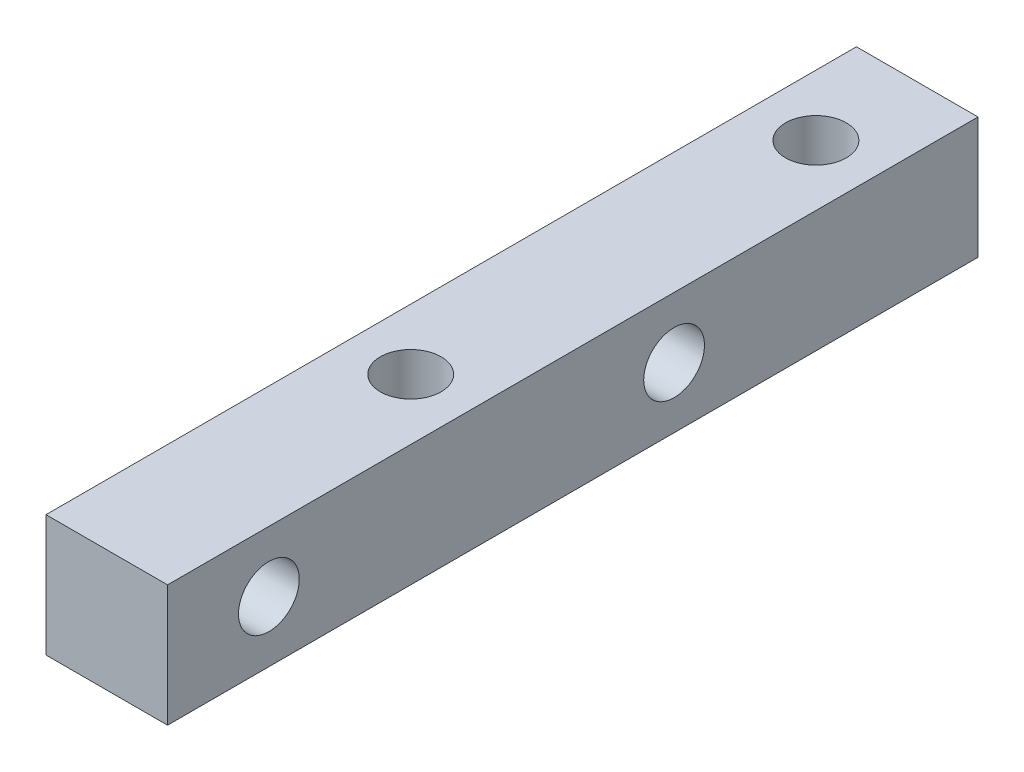
from build123d import *

# Parameters (mm, degrees)
SKETCH_1_W          = 6
SKETCH_1_H          = 6
EXTRUDE_1_DEPTH     = 40
SKETCH_2_R          = 1.5
CUT_EXTRUDE_1_DEPTH = 50
SKETCH_3_R          = 1.5
CUT_EXTRUDE_2_DEPTH = 50


with BuildPart() as part:
    # 草图1 → 凸台-拉伸1 (new body)
    with BuildSketch(Plane.XY):
        with Locations((3, 3)):
            Rectangle(SKETCH_1_W, SKETCH_1_H)
    extrude(amount=EXTRUDE_1_DEPTH)

    # 草图2 → 切除-拉伸1 (cut)
    with BuildSketch(Plane(origin=(0, 6, 0), x_dir=(1, 0, 0), z_dir=(0, 1, 0))):
        with Locations((3, -5)):
            Circle(SKETCH_2_R)
        with Locations((3, -25)):
            Circle(SKETCH_2_R)
    extrude(amount=-CUT_EXTRUDE_1_DEPTH, mode=Mode.SUBTRACT)

    # 草图3 → 切除-拉伸2 (cut)
    with BuildSketch(Plane.ZY):
        with Locations((35, 3)):
            Circle(SKETCH_3_R)
        with Locations((15, 3)):
            Circle(SKETCH_3_R)
    extrude(amount=-CUT_EXTRUDE_2_DEPTH, mode=Mode.SUBTRACT)


solid = part.part
